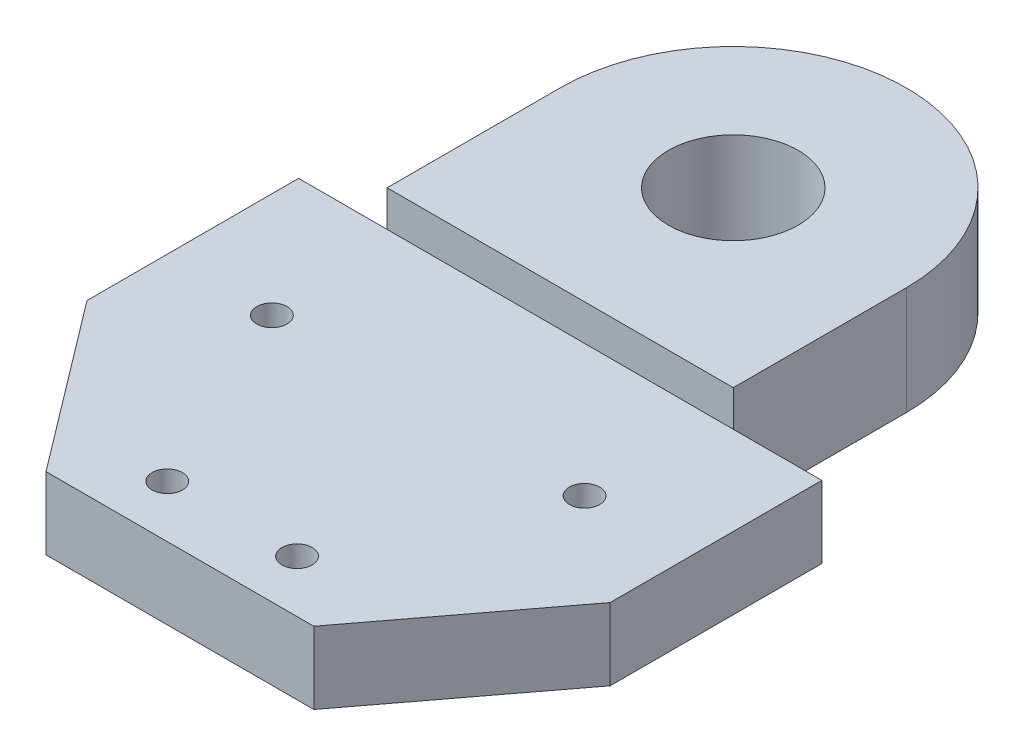
from build123d import *

# Parameters (mm, degrees)
SKETCH1_R           = 1.75
BOSS_EXTRUDE1_DEPTH = 8.333333333
SKETCH2_R           = 7.5
BOSS_EXTRUDE2_DEPTH = 12.5


with BuildPart() as part:
    # Sketch1 → Boss-Extrude1 (new body)
    with BuildSketch(Plane(origin=(0, 0, 0), x_dir=(1, 0, 0), z_dir=(0, 1, 0))):
        Polygon((-30.225021847, 13.45402847), (-15.473485445, -6.035190955), (15.473485445, -6.035190955), (30.225021847, 13.45402847), (30.225021847, 37.907694676), (18.065456544, 37.907694676), (-18.065456544, 37.907694676), (-30.225021847, 37.907694676), align=None)
        with Locations((-18.065456544, 22.657694676)):
            Circle(SKETCH1_R, mode=Mode.SUBTRACT)
        with Locations((18.065456544, 22.657694676)):
            Circle(SKETCH1_R, mode=Mode.SUBTRACT)
        with Locations((7.5, 0)):
            Circle(SKETCH1_R, mode=Mode.SUBTRACT)
        with Locations((-7.5, 0)):
            Circle(SKETCH1_R, mode=Mode.SUBTRACT)
    extrude(amount=BOSS_EXTRUDE1_DEPTH)

    # Sketch2 → Boss-Extrude2 (add)
    with BuildSketch(Plane(origin=(0, 0, 0), x_dir=(1, 0, 0), z_dir=(0, 1, 0))):
        with BuildLine():
            Line((-20, 57.907694676), (-20, 37.907694676))
            Line((-20, 37.907694676), (20, 37.907694676))
            Line((20, 37.907694676), (20, 57.907694676))
            ThreePointArc((20, 57.907694676), (0, 77.907694676), (-20, 57.907694676))
        make_face()
        with Locations((0, 57.907694676)):
            Circle(SKETCH2_R, mode=Mode.SUBTRACT)
    extrude(amount=BOSS_EXTRUDE2_DEPTH)


solid = part.part
